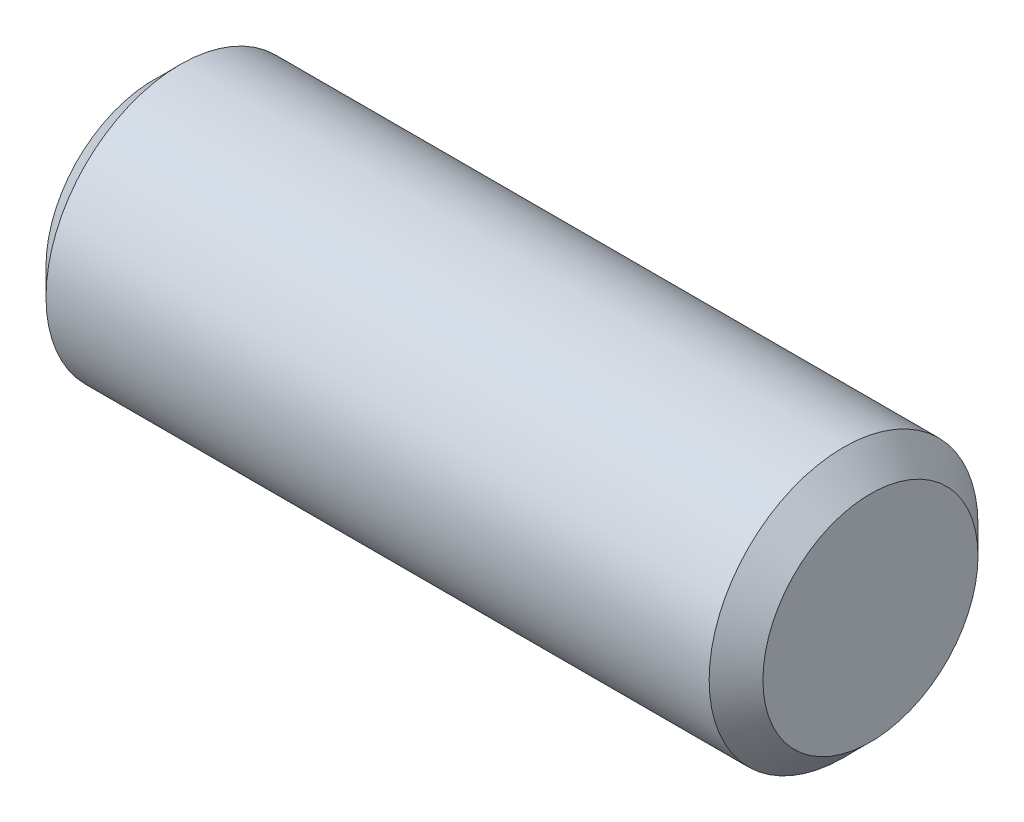
from build123d import *

# Parameters (mm, degrees)
SKETCH2_R           = 2.38125
EXTRUDE1_DEPTH      = 6.35
EXTRUDE1_DEPTH_BACK = 6.35
CHAMFER1_SIZE       = 0.47625


with BuildPart() as part:
    # Sketch2 → Extrude1 (new body, two sides)
    with BuildSketch(Plane(origin=(0, 0, 0), x_dir=(0, 0, -1), z_dir=(1, 0, 0))) as extrude1_sk:
        Circle(SKETCH2_R)
    extrude(amount=EXTRUDE1_DEPTH)
    extrude(extrude1_sk.sketch, amount=-EXTRUDE1_DEPTH_BACK)

    # Chamfer1
    chamfer1_edges = [part.edges().sort_by_distance(p)[0] for p in [
        (-6.35, 0, 2.38125),
        (6.35, 0, 2.38125),
    ]]
    chamfer(chamfer1_edges, length=CHAMFER1_SIZE)


solid = part.part
